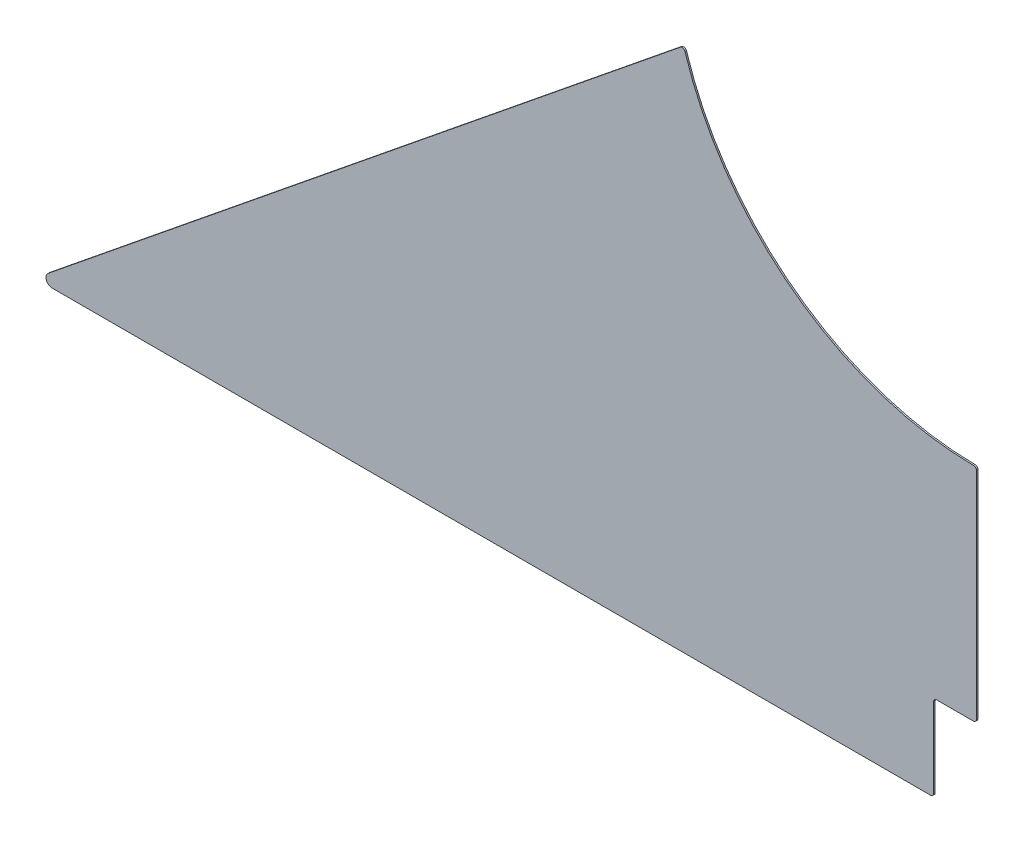
from build123d import *

# Parameters (mm, degrees)
BOSS_EXTRUDE1_DEPTH = 1.5875
SKETCH2_W           = 88.9
SKETCH2_H           = 342.9
CUT_EXTRUDE1_DEPTH  = 2.5875
SKETCH4_W           = 1292.225
SKETCH4_H           = 800.002961837
CUT_EXTRUDE2_DEPTH  = 2.5875
CUT_EXTRUDE3_DEPTH  = 2.5875
FILLET1_R           = 3.175
FILLET2_R           = 6.35


with BuildPart() as part:
    # Sketch1 → Boss-Extrude1 (new body)
    with BuildSketch(Plane.XY):
        with BuildLine():
            Line((1292.225, 0), (-1292.225, 0))
            Line((-1292.225, 0), (-304.303617208, 800.002961837))
            ThreePointArc((-304.303617208, 800.002961837), (0, 573.0875), (304.303617208, 800.002961837))
            Line((304.303617208, 800.002961837), (1292.225, 0))
        make_face()
    extrude(amount=BOSS_EXTRUDE1_DEPTH)

    # Sketch2 → Cut-Extrude1 (cut, through all)
    with BuildSketch(Plane.XY.offset(1.5875)):
        with Locations((0, 171.45)):
            Rectangle(SKETCH2_W, SKETCH2_H)
    extrude(amount=-CUT_EXTRUDE1_DEPTH, mode=Mode.SUBTRACT)

    # Sketch4 → Cut-Extrude2 (cut, through all)
    with BuildSketch(Plane.XY.offset(1.5875)):
        with Locations((646.1125, 400.001480919)):
            Rectangle(SKETCH4_W, SKETCH4_H)
    extrude(amount=-CUT_EXTRUDE2_DEPTH, mode=Mode.SUBTRACT)

    # Sketch5 → Cut-Extrude3 (cut, through all)
    with BuildSketch(Plane.XY.offset(1.5875)):
        Polygon((-44.45, 253.902961837), (-978.680954392, 253.902961837), (-1292.225, 0), (-44.45, 0), align=None)
    extrude(amount=-CUT_EXTRUDE3_DEPTH, mode=Mode.SUBTRACT)

    # Fillet1
    fillet1_edges = [part.edges().sort_by_distance(p)[0] for p in [
        (-44.45, 342.9, 0.79375),
        (0, 342.9, 0.79375),
        (0, 573.0875, 0.79375),
        (-44.45, 253.902961837, 0.79375),
        (-304.303617208, 800.002961837, 0.79375),
    ]]
    fillet(fillet1_edges, radius=FILLET1_R)

    # Fillet2
    fillet2_edges = [part.edges().sort_by_distance(p)[0] for p in [
        (-978.680954392, 253.902961837, 0.79375),
    ]]
    fillet(fillet2_edges, radius=FILLET2_R)


solid = part.part
